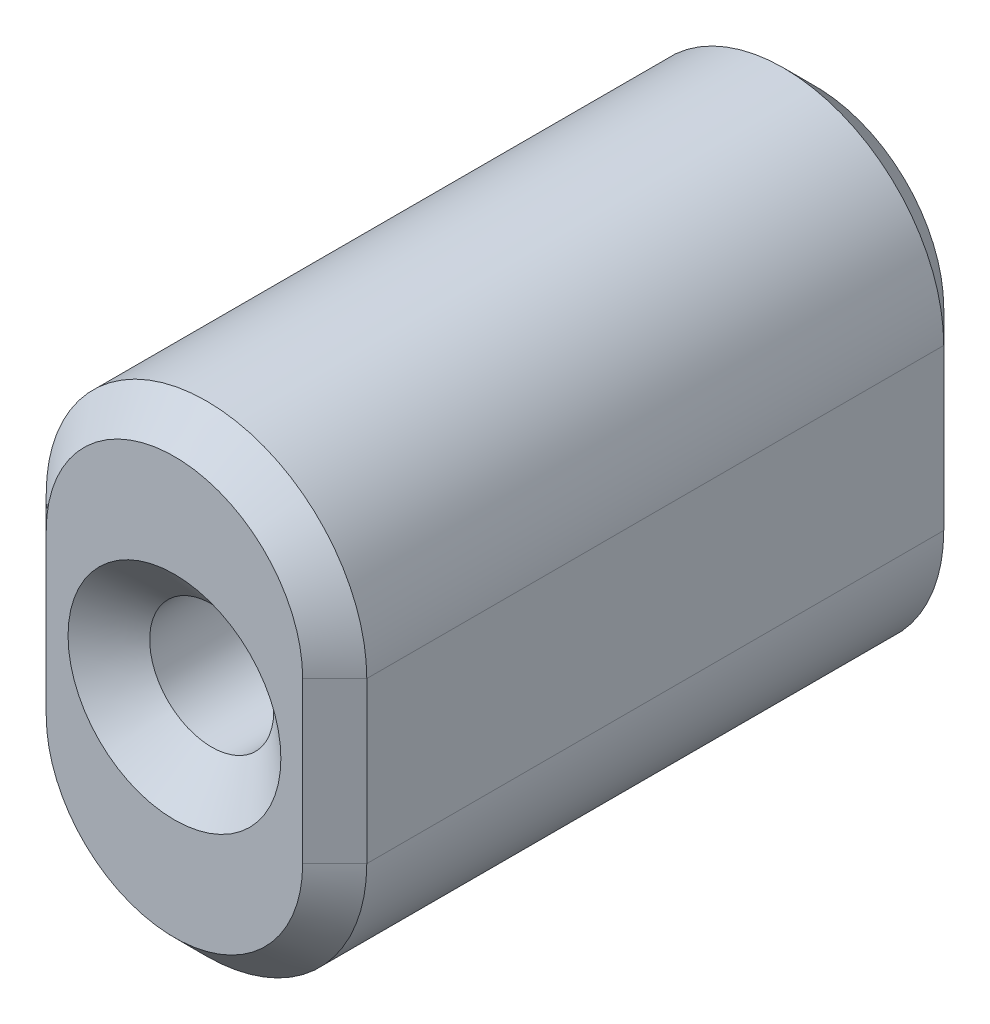
from build123d import *

# Parameters (mm, degrees)
BOSS_EXTRUDE1_DEPTH                               = 25.4
CHAMFER1_SIZE                                     = 1.27
CSK_FOR_8_FLAT_HEAD_MACHINE_SCREW_100_D           = 4.9149
CSK_FOR_8_FLAT_HEAD_MACHINE_SCREW_100_CSINK_D     = 8.4328
CSK_FOR_8_FLAT_HEAD_MACHINE_SCREW_100_CSINK_ANGLE = 100


with BuildPart() as part:
    # Sketch1 → Boss-Extrude1 (new body)
    with BuildSketch(Plane.XY):
        with BuildLine():
            Line((-6.35, -3.175), (-6.35, 3.175))
            ThreePointArc((-6.35, 3.175), (0, 9.525), (6.35, 3.175))
            Line((6.35, 3.175), (6.35, -3.175))
            ThreePointArc((6.35, -3.175), (0, -9.525), (-6.35, -3.175))
        make_face()
    extrude(amount=BOSS_EXTRUDE1_DEPTH)

    # Chamfer1
    chamfer1_edges = [part.edges().sort_by_distance(p)[0] for p in [
        (0, 9.525, 25.4),
        (-6.35, 0, 25.4),
        (0, -9.525, 25.4),
        (-6.35, 0, 0),
        (0, 9.525, 0),
        (6.35, 0, 0),
        (0, -9.525, 0),
        (6.35, 0, 25.4),
    ]]
    chamfer(chamfer1_edges, length=CHAMFER1_SIZE)

    # CSK for #8 Flat Head Machine Screw (100)1 (through all)
    with Locations(Plane.XY.offset(25.4)):
        with Locations((0, 0)):
            CounterSinkHole(CSK_FOR_8_FLAT_HEAD_MACHINE_SCREW_100_D / 2, CSK_FOR_8_FLAT_HEAD_MACHINE_SCREW_100_CSINK_D / 2, counter_sink_angle=CSK_FOR_8_FLAT_HEAD_MACHINE_SCREW_100_CSINK_ANGLE)


solid = part.part
